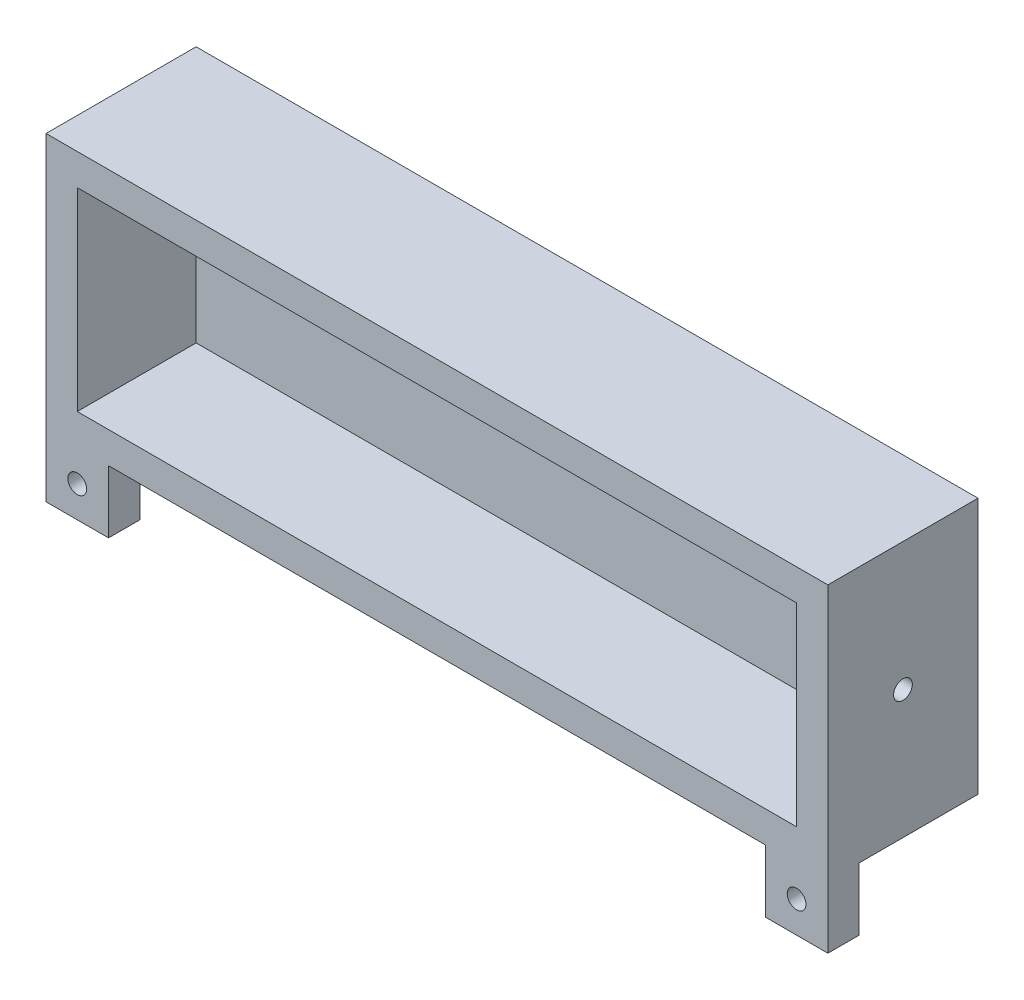
from build123d import *

# Parameters (mm, degrees)
SKETCH1_W           = 115
SKETCH1_H           = 31
BOSS_EXTRUDE1_DEPTH = 19
SHELL1_T            = 5
SKETCH2_R           = 1.5
CUT_EXTRUDE1_DEPTH  = 19
SKETCH3_W           = 10
SKETCH3_H           = 5
BOSS_EXTRUDE2_DEPTH = 10
SKETCH4_R           = 1.5
CUT_EXTRUDE2_DEPTH  = 127.716218378


with BuildPart() as part:
    # Sketch1 → Boss-Extrude1 (new body)
    with BuildSketch(Plane.XY):
        with Locations((57.5, 15.5)):
            Rectangle(SKETCH1_W, SKETCH1_H)
    extrude(amount=BOSS_EXTRUDE1_DEPTH)

    # Shell1
    shell1_openings = [part.faces().sort_by_distance(p)[0] for p in [
        (57.5, 15.5, 19),
    ]]
    offset(amount=SHELL1_T, openings=shell1_openings, kind=Kind.INTERSECTION)

    # Sketch2 → Cut-Extrude1 (cut)
    with BuildSketch(Plane(origin=(120, 0, 0), x_dir=(0, 0, -1), z_dir=(1, 0, 0))):
        with Locations((-7, 15.5)):
            Circle(SKETCH2_R)
    extrude(amount=-CUT_EXTRUDE1_DEPTH, mode=Mode.SUBTRACT)

    # Sketch3 → Boss-Extrude2 (add)
    with BuildSketch(Plane(origin=(0, -5, 0), x_dir=(-1, 0, 0), z_dir=(0, -1, 0))):
        with Locations((0, -16.5)):
            Rectangle(SKETCH3_W, SKETCH3_H)
        with Locations((-115, -16.5)):
            Rectangle(SKETCH3_W, SKETCH3_H)
    extrude(amount=BOSS_EXTRUDE2_DEPTH)

    # Sketch4 → Cut-Extrude2 (cut, through all)
    with BuildSketch(Plane(origin=(0, 0, 14), x_dir=(-1, 0, 0), z_dir=(0, 0, -1))):
        with Locations((0, -10)):
            Circle(SKETCH4_R)
        with Locations((-115, -10)):
            Circle(SKETCH4_R)
    extrude(amount=-CUT_EXTRUDE2_DEPTH, mode=Mode.SUBTRACT)


solid = part.part
